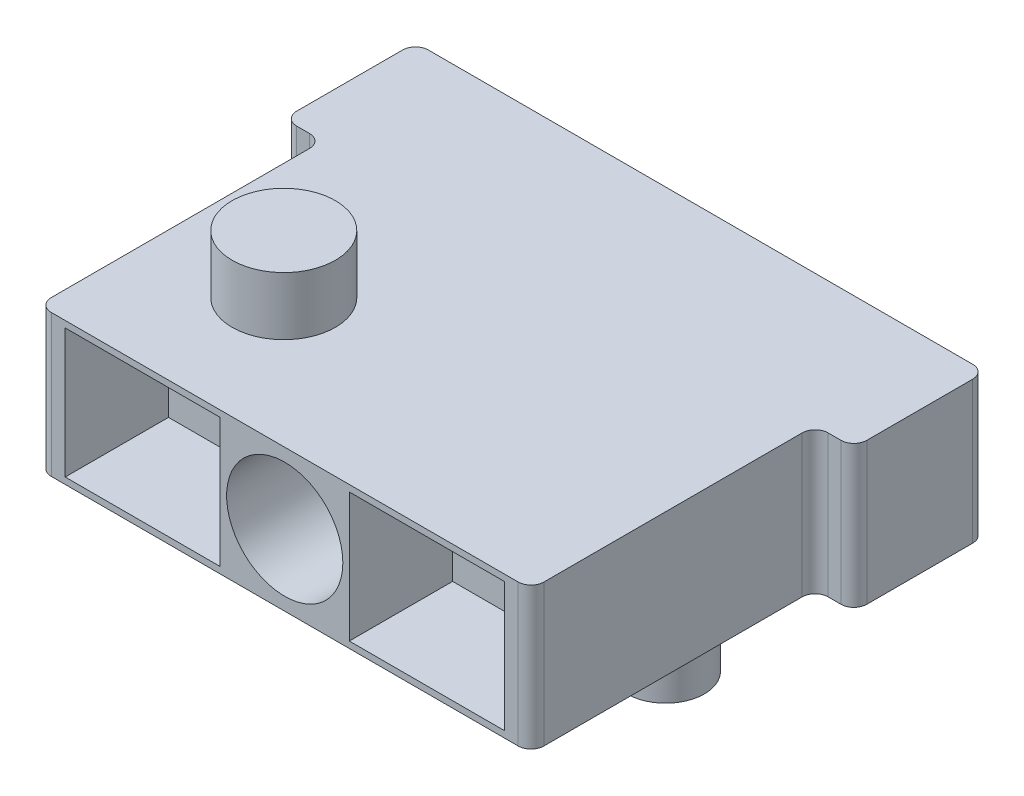
from build123d import *

# Parameters (mm, degrees)
SKETCH_2_W          = 44.15
SKETCH_2_H          = 11
EXTRUDE_1_DEPTH     = 32.2
SKETCH_3_R          = 3
EXTRUDE_2_DEPTH     = 4.5
M3X0_5_1_D          = 2.5
M3X0_5_1_DEPTH      = 5
M3X0_5_1_TIP        = 0.751075774
SKETCH_7_R          = 4
EXTRUDE_3_DEPTH     = 4.5
SKETCH_8_W          = 3
SKETCH_8_H          = 22
CUT_EXTRUDE_1_DEPTH = 16.5
SKETCH_9_W          = 12
SKETCH_9_H          = 10
CUT_EXTRUDE_2_DEPTH = 8
SKETCH_10_R         = 4.5
CUT_EXTRUDE_3_DEPTH = 10
FILLET_1_R          = 1


with BuildPart() as part:
    # 草圖2 → 填料-伸長1 (new body)
    with BuildSketch(Plane.XY):
        Rectangle(SKETCH_2_W, SKETCH_2_H)
    extrude(amount=-EXTRUDE_1_DEPTH)

    # 草圖3 → 填料-伸長2 (add)
    with BuildSketch(Plane.XZ.offset(5.5)):
        with Locations((-14.3, -15.2)):
            Circle(SKETCH_3_R)
        with Locations((14.3, -15.2)):
            Circle(SKETCH_3_R)
    extrude(amount=EXTRUDE_2_DEPTH)

    # M3x0.5  螺絲攻的螺孔鑽1
    with Locations(Plane(origin=(0, -10, 0), x_dir=(-1, 0, 0), z_dir=(0, -1, 0))):
        with Locations((14.3, 15.2), (-14.3, 15.2)):
            Hole(M3X0_5_1_D / 2, depth=M3X0_5_1_DEPTH)
            with Locations((0, 0, -(M3X0_5_1_DEPTH + M3X0_5_1_TIP / 2))):  # 118° drill point
                Cone(0, M3X0_5_1_D / 2, M3X0_5_1_TIP, mode=Mode.SUBTRACT)

    # 草圖7 → 填料-伸長3 (add)
    with BuildSketch(Plane(origin=(0, 5.5, 0), x_dir=(1, 0, 0), z_dir=(0, 1, 0))):
        with Locations((-10.075, 10)):
            Circle(SKETCH_7_R)
    extrude(amount=EXTRUDE_3_DEPTH)

    # 草圖8 → 除料-伸長1 (cut, through all)
    with BuildSketch(Plane(origin=(0, 5.5, 0), x_dir=(1, 0, 0), z_dir=(0, 1, 0))):
        with Locations((-20.575, 11)):
            Rectangle(SKETCH_8_W, SKETCH_8_H)
        with Locations((20.575, 11)):
            Rectangle(SKETCH_8_W, SKETCH_8_H)
    extrude(amount=-CUT_EXTRUDE_1_DEPTH, mode=Mode.SUBTRACT)

    # 草圖9 → 除料-伸長2 (cut)
    with BuildSketch(Plane.XY):
        with Locations((-11, 0)):
            Rectangle(SKETCH_9_W, SKETCH_9_H)
        with Locations((11, 0)):
            Rectangle(SKETCH_9_W, SKETCH_9_H)
    extrude(amount=-CUT_EXTRUDE_2_DEPTH, mode=Mode.SUBTRACT)

    # 草圖10 → 除料-伸長3 (cut)
    with BuildSketch(Plane.XY):
        Circle(SKETCH_10_R)
    extrude(amount=-CUT_EXTRUDE_3_DEPTH, mode=Mode.SUBTRACT)

    # 圓角1
    fillet_1_edges = [part.edges().sort_by_distance(p)[0] for p in [
        (-22.075, 0, -32.2),
        (19.075, 0, 0),
        (-19.075, 0, 0),
        (22.075, 0, -32.2),
        (-22.075, 0, -22),
        (-19.075, 0, -22),
        (22.075, 0, -22),
        (19.075, 0, -22),
    ]]
    fillet(fillet_1_edges, radius=FILLET_1_R)


solid = part.part
